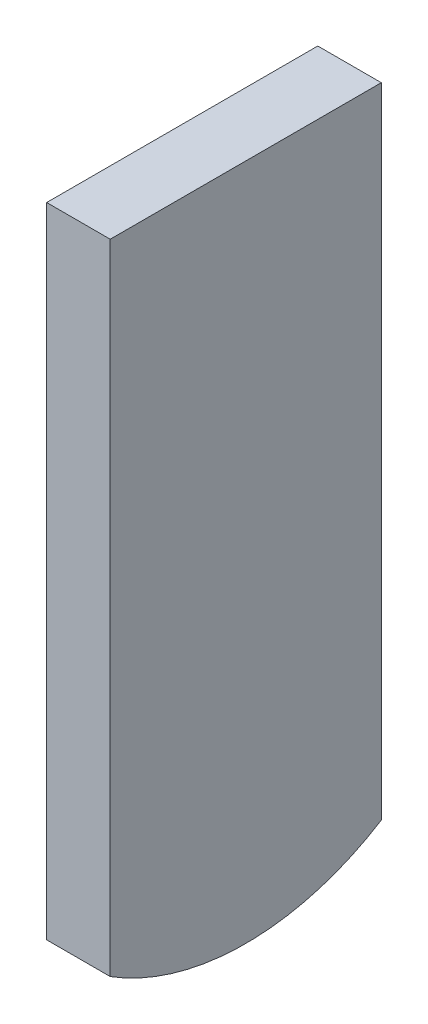
from build123d import *

# Parameters (mm, degrees)
SPIN_W           = 1.5
SPIN_H           = 6.4
FPIN_DEPTH       = 16
FPIN2_DEPTH      = 1.75
FPIN2_DEPTH_BACK = 1.75


with BuildPart() as part:
    # SPin → FPin (new body)
    with BuildSketch(Plane(origin=(0, 0, 0), x_dir=(1, 0, 0), z_dir=(0, 1, 0))):
        Rectangle(SPIN_W, SPIN_H)
    extrude(amount=-FPIN_DEPTH)

    # SPin2 → FPin2 (cut, two sides)
    with BuildSketch(Plane(origin=(0, 0, 0), x_dir=(0, 0, -1), z_dir=(1, 0, 0))) as fpin2_sk:
        with BuildLine():
            Line((-39.366991309, 7.727434754), (-3.2, -15.075431016))
            ThreePointArc((-3.2, -15.075431016), (0, -16), (3.2, -15.075431016))
            Line((3.2, -15.075431016), (39.366991309, 7.727434754))
            Line((39.366991309, 7.727434754), (39.366991309, -77.783311885))
            Line((39.366991309, -77.783311885), (-39.366991309, -77.783311885))
            Line((-39.366991309, -77.783311885), (-39.366991309, 7.727434754))
        make_face()
    extrude(amount=FPIN2_DEPTH, mode=Mode.SUBTRACT)
    extrude(fpin2_sk.sketch, amount=-FPIN2_DEPTH_BACK, mode=Mode.SUBTRACT)


solid = part.part
